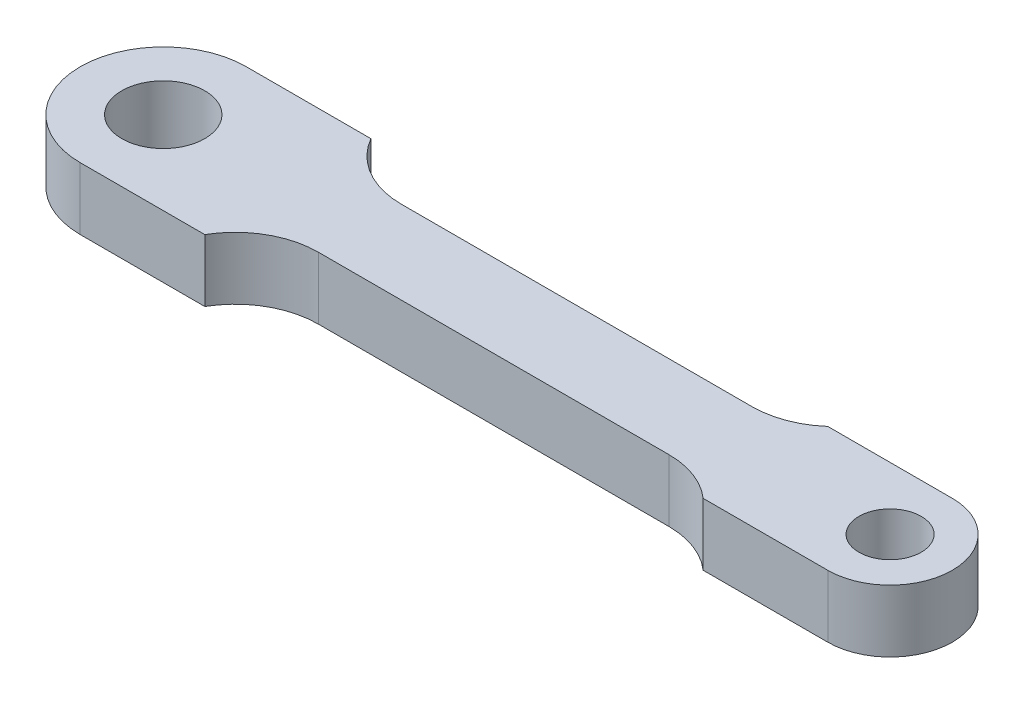
from build123d import *

# Parameters (mm, degrees)
SKETCH1_R           = 2
SKETCH1_R_2         = 1.5
BOSS_EXTRUDE1_DEPTH = 1.5


with BuildPart() as part:
    # Sketch1 → Boss-Extrude1 (new body, symmetric)
    with BuildSketch(Plane(origin=(0, 0, 0), x_dir=(1, 0, 0), z_dir=(0, 1, 0))):
        with BuildLine():
            Line((-10.519623347, 4), (-4.519623347, 4))
            ThreePointArc((-4.519623347, 4), (-3.055521732, 2.535898385), (-1.055521732, 2))
            Line((-1.055521732, 2), (15.834625342, 2))
            ThreePointArc((15.834625342, 2), (17.248838905, 2.258342613), (18.480376653, 3))
            Line((18.480376653, 3), (24.480376653, 3))
            ThreePointArc((24.480376653, 3), (27.480376653, 0), (24.480376653, -3))
            Line((24.480376653, -3), (18.480376653, -3))
            ThreePointArc((18.480376653, -3), (17.248838905, -2.258342613), (15.834625342, -2))
            Line((15.834625342, -2), (-1.055521732, -2))
            ThreePointArc((-1.055521732, -2), (-3.055521732, -2.535898385), (-4.519623347, -4))
            Line((-4.519623347, -4), (-10.519623347, -4))
            ThreePointArc((-10.519623347, -4), (-14.519623347, 0), (-10.519623347, 4))
        make_face()
        with Locations((-10.519623347, 0)):
            Circle(SKETCH1_R, mode=Mode.SUBTRACT)
        with Locations((24.480376653, 0)):
            Circle(SKETCH1_R_2, mode=Mode.SUBTRACT)
    extrude(amount=BOSS_EXTRUDE1_DEPTH, both=True)


solid = part.part
